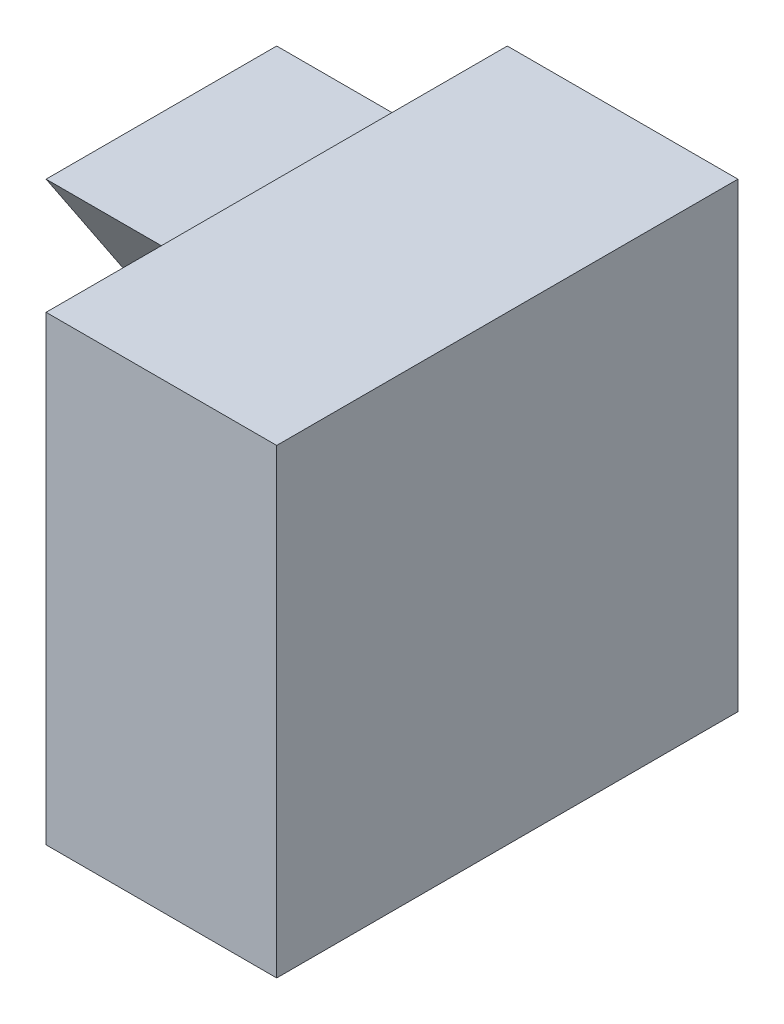
from build123d import *

# Parameters (mm, degrees)
SKETCH1_W           = 4
SKETCH1_H           = 4
BOSS_EXTRUDE1_DEPTH = 2
SKETCH2_W           = 2
SKETCH2_H           = 3
BOSS_EXTRUDE2_DEPTH = 2
CUT_EXTRUDE1_DEPTH  = 2


with BuildPart() as part:
    # Sketch1 → Boss-Extrude1 (new body)
    with BuildSketch(Plane(origin=(0, 0, 0), x_dir=(0, 0, -1), z_dir=(1, 0, 0))):
        with Locations((2, 2)):
            Rectangle(SKETCH1_W, SKETCH1_H)
    extrude(amount=BOSS_EXTRUDE1_DEPTH)

    # Sketch2 → Boss-Extrude2 (add)
    with BuildSketch(Plane.ZY):
        with Locations((-3, 1.5)):
            Rectangle(SKETCH2_W, SKETCH2_H)
    extrude(amount=BOSS_EXTRUDE2_DEPTH)

    # Sketch3 → Cut-Extrude1 (cut)
    with BuildSketch(Plane.ZY.offset(2)):
        Polygon((-2, 3), (-4, 0), (-2, 0), align=None)
    extrude(amount=-CUT_EXTRUDE1_DEPTH, mode=Mode.SUBTRACT)


solid = part.part
